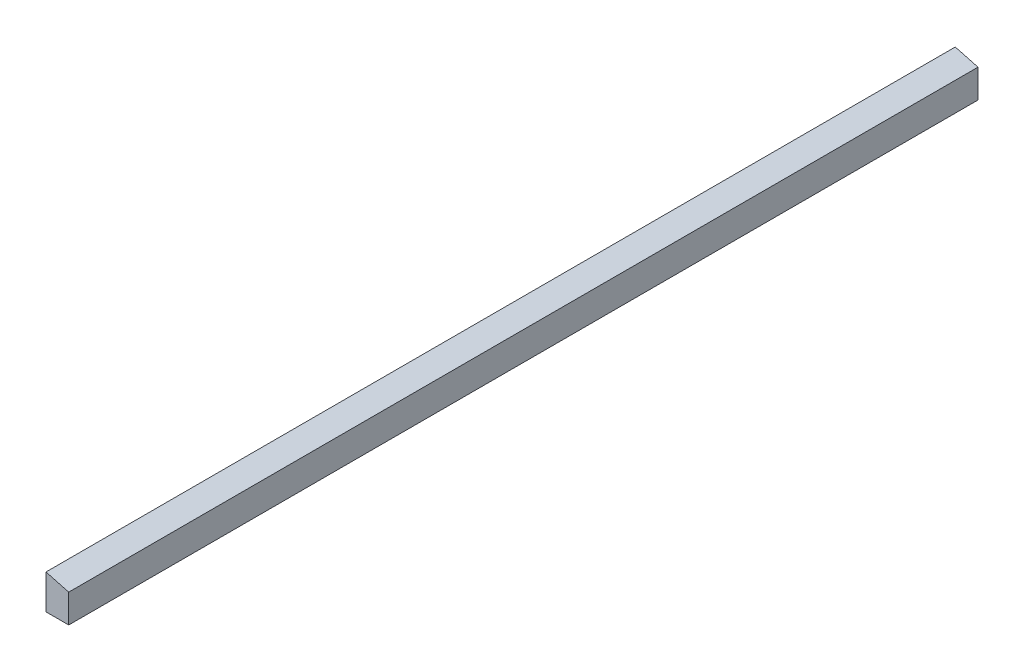
from build123d import *

# Parameters (mm, degrees)
BOSS_EXTRUDE1_DEPTH = 1524


with BuildPart() as part:
    # Sketch1 → Boss-Extrude1 (new body)
    with BuildSketch(Plane.XY):
        Polygon((-22.760638199, 27.433275777), (15.339361801, 17.224411546), (15.339361801, -30.510474223), (-22.760638199, -30.510474223), align=None)
    extrude(amount=BOSS_EXTRUDE1_DEPTH)


solid = part.part
